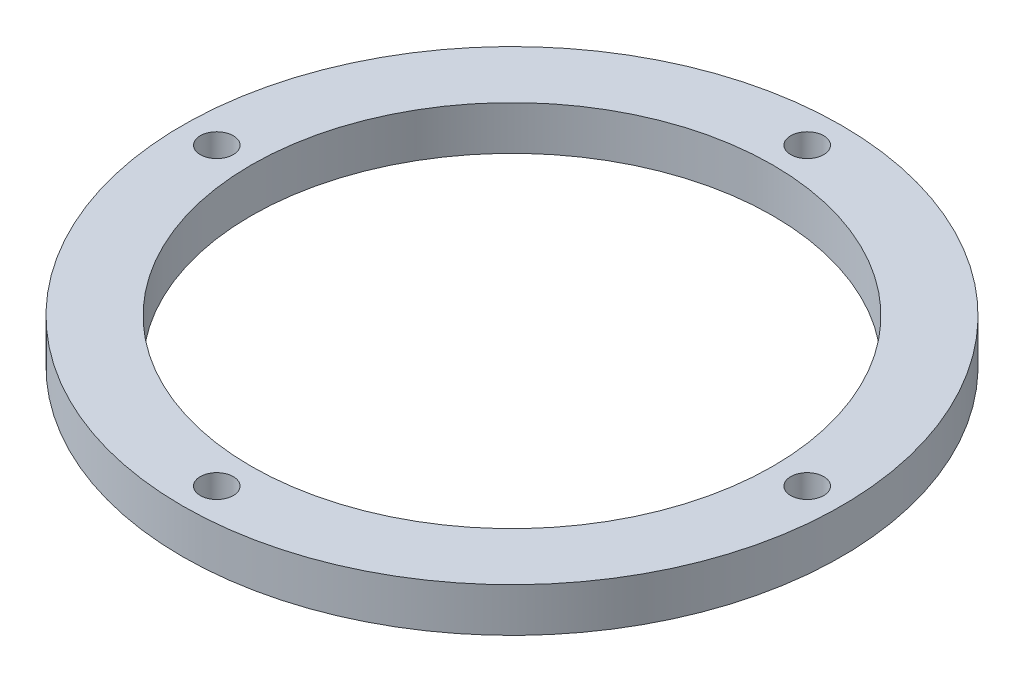
from build123d import *

# Parameters (mm, degrees)
SKETCH_1_R      = 60
SKETCH_1_R_2    = 47.5
SKETCH_1_R_3    = 3
EXTRUDE_1_DEPTH = 8


with BuildPart() as part:
    # 草图1 → 凸台-拉伸1 (new body)
    with BuildSketch(Plane(origin=(0, 0, 0), x_dir=(1, 0, 0), z_dir=(0, 1, 0))):
        Circle(SKETCH_1_R)
        Circle(SKETCH_1_R_2, mode=Mode.SUBTRACT)
        with Locations((53.75, 0)):
            Circle(SKETCH_1_R_3, mode=Mode.SUBTRACT)
        with Locations((0, -53.75)):
            Circle(SKETCH_1_R_3, mode=Mode.SUBTRACT)
        with Locations((-53.75, 0)):
            Circle(SKETCH_1_R_3, mode=Mode.SUBTRACT)
        with Locations((0, 53.75)):
            Circle(SKETCH_1_R_3, mode=Mode.SUBTRACT)
    extrude(amount=EXTRUDE_1_DEPTH)


solid = part.part
